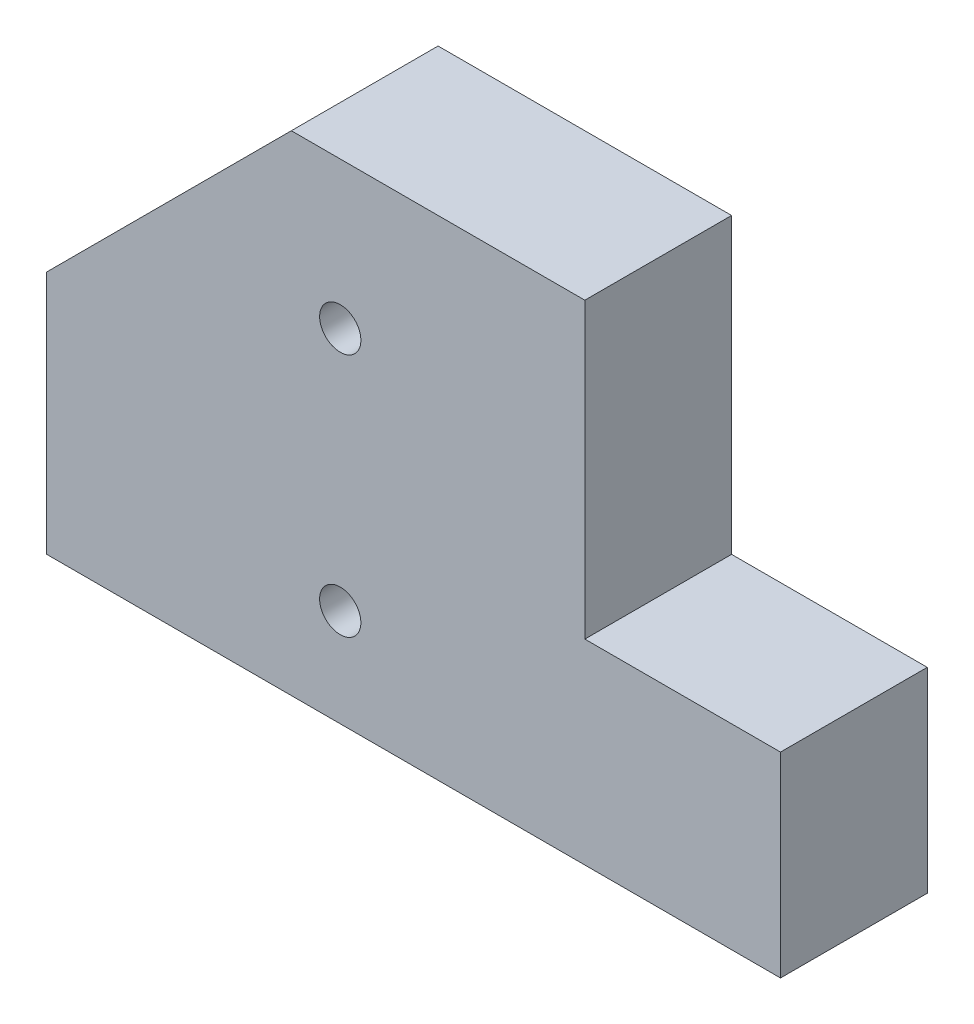
from build123d import *

# Parameters (mm, degrees)
SALIENTE_EXTRUIR1_DEPTH            = 30
TALADRO_DE_MARGEN_PARA_5_161_D     = 8.4328
TALADRO_DE_MARGEN_PARA_5_161_DEPTH = 25.4
TALADRO_DE_MARGEN_PARA_5_161_TIP   = 2.533468714


with BuildPart() as part:
    # Croquis1 → Saliente-Extruir1 (new body)
    with BuildSketch(Plane.XY):
        Polygon((0, 0), (0, 50), (50, 100), (110, 100), (110, 40), (150, 40), (150, 0), align=None)
    extrude(amount=SALIENTE_EXTRUIR1_DEPTH)

    # Taladro de margen para 5/161
    with Locations(Plane(origin=(60, 70, 30), x_dir=(1, 0, 0), z_dir=(0, 0, 1))):
        with Locations((0, 0), (0, -50)):
            Hole(TALADRO_DE_MARGEN_PARA_5_161_D / 2, depth=TALADRO_DE_MARGEN_PARA_5_161_DEPTH)
            with Locations((0, 0, -(TALADRO_DE_MARGEN_PARA_5_161_DEPTH + TALADRO_DE_MARGEN_PARA_5_161_TIP / 2))):  # 118° drill point
                Cone(0, TALADRO_DE_MARGEN_PARA_5_161_D / 2, TALADRO_DE_MARGEN_PARA_5_161_TIP, mode=Mode.SUBTRACT)


solid = part.part
